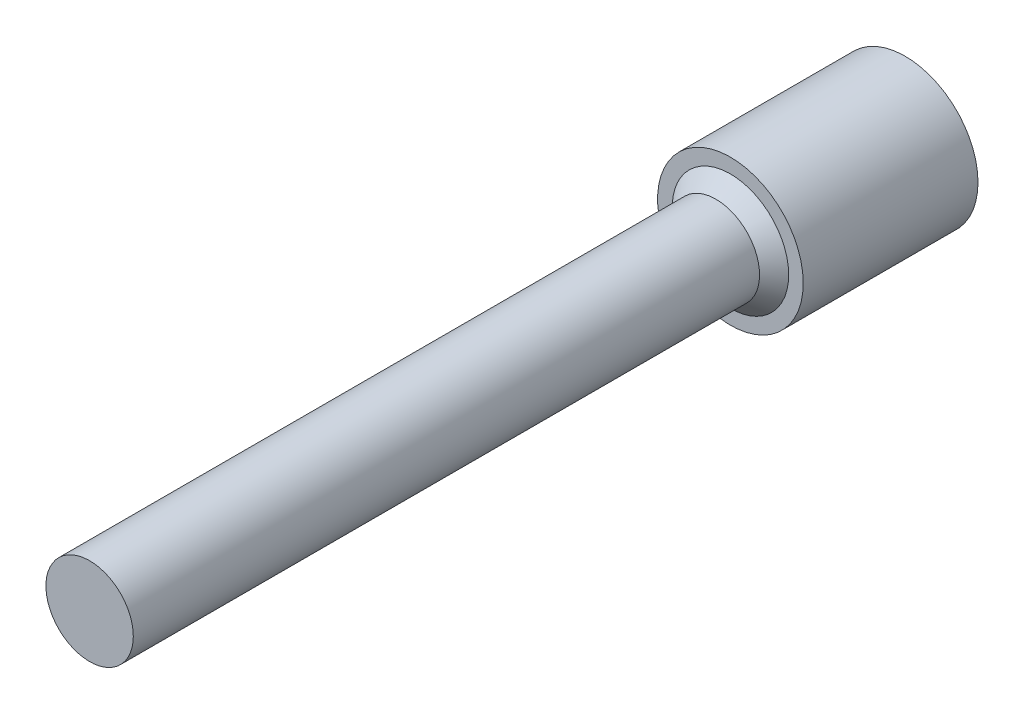
from build123d import *

# Parameters (mm, degrees)
SKETCH1_R           = 2.5
BOSS_EXTRUDE1_DEPTH = 6
SKETCH2_R           = 1.5
BOSS_EXTRUDE2_DEPTH = 22
CUT_EXTRUDE1_DEPTH  = 1
CHAMFER1_SIZE       = 0.5


with BuildPart() as part:
    # Sketch1 → Boss-Extrude1 (new body)
    with BuildSketch(Plane.XY):
        Circle(SKETCH1_R)
    extrude(amount=BOSS_EXTRUDE1_DEPTH)

    # Sketch2 → Boss-Extrude2 (add)
    with BuildSketch(Plane.XY.offset(6)):
        Circle(SKETCH2_R)
    extrude(amount=BOSS_EXTRUDE2_DEPTH)

    # Sketch3 → Cut-Extrude1 (cut)
    with BuildSketch(Plane(origin=(0, 0, 0), x_dir=(-1, 0, 0), z_dir=(0, 0, -1))):
        Polygon((0, 1), (-0.866025404, 0.5), (-0.866025404, -0.5), (0, -1), (0.866025404, -0.5), (0.866025404, 0.5), align=None)
    extrude(amount=-CUT_EXTRUDE1_DEPTH, mode=Mode.SUBTRACT)

    # Chamfer1
    chamfer1_edges = [part.edges().sort_by_distance(p)[0] for p in [
        (-1.5, 0, 6),
    ]]
    chamfer(chamfer1_edges, length=CHAMFER1_SIZE)


solid = part.part
